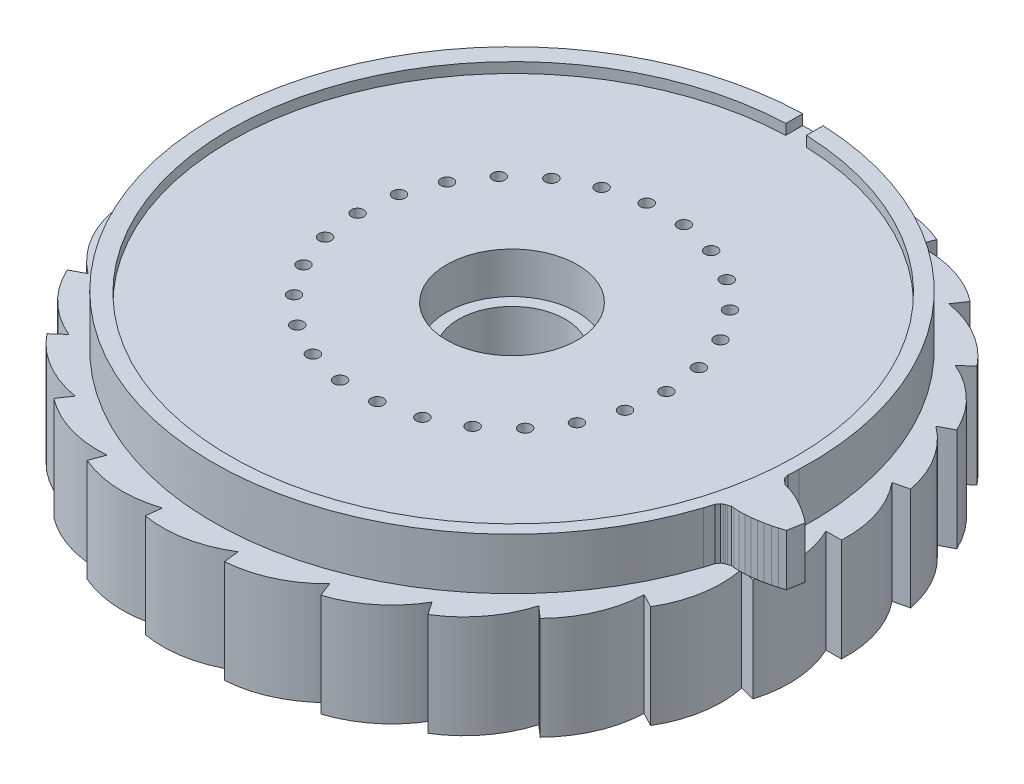
from build123d import *

# Parameters (mm, degrees)
EXTRUDE_RATCHET_EDGE_DEPTH      = 10
PATTERN_EDGE_TO_FORM_GEAR_COUNT = 26
GEAR_FACE_DEPTH                 = 5
PCB_INSET_DEPTH                 = 1
SKETCH7_R                       = 6.35
CUT_BEARING_HOLE_DEPTH          = 5
PCB_INSET_REAR_DEPTH            = 1
PIN_HOLES_R                     = 0.6
PIN_HOLES_CUT_DEPTH             = 15
SKETCH15_R                      = 5.18
CUT_EXTRUDE3_DEPTH              = 16


with BuildPart() as part:
    # Sketch1 → Extrude ratchet edge (new body)
    with BuildSketch(Plane(origin=(0, 0, 0), x_dir=(1, 0, 0), z_dir=(0, 1, 0))):
        with BuildLine():
            Line((0, 0), (29.613725431, 7.299127761))
            ThreePointArc((29.613725431, 7.299127761), (31.486736206, 3.871832194), (32, 0))
            Line((32, 0), (0, 0))
        make_face()
    extrude_ratchet_edge = extrude(amount=EXTRUDE_RATCHET_EDGE_DEPTH)

    # Pattern edge to form gear: Extrude ratchet edge ×26 about axis
    pattern_edge_to_form_gear_axis = Axis((0, 0, 0), (0, 1, 0))
    for i in range(1, PATTERN_EDGE_TO_FORM_GEAR_COUNT):
        add(extrude_ratchet_edge.rotate(pattern_edge_to_form_gear_axis, i * 360 / PATTERN_EDGE_TO_FORM_GEAR_COUNT))

    # Sketch12 → Gear face (add)
    with BuildSketch(Plane(origin=(0, 10, 0), x_dir=(1, 0, 0), z_dir=(0, 1, 0))):
        with BuildLine():
            Line((28.927375325, -2.125741727), (29.026395325, -2.515151727))
            Line((29.026395325, -2.515151727), (29.142735325, -2.671831727))
            Line((29.142735325, -2.671831727), (29.262305325, -2.787261727))
            Line((29.262305325, -2.787261727), (29.383725325, -2.880131727))
            Line((29.383725325, -2.880131727), (29.624225325, -3.082071727))
            Line((29.624225325, -3.082071727), (29.879175325, -3.139941727))
            Line((29.879175325, -3.139941727), (30.384275325, -3.299211727))
            Line((30.384275325, -3.299211727), (30.884385325, -3.499611727))
            Line((30.884385325, -3.499611727), (31.379885325, -3.733371727))
            Line((31.379885325, -3.733371727), (31.870755325, -3.996551727))
            Line((31.870755325, -3.996551727), (32.356805325, -4.286661727))
            Line((32.356805325, -4.286661727), (32.837785325, -4.602001727))
            Line((32.837785325, -4.602001727), (33.313375325, -4.941291727))
            Line((33.313375325, -4.941291727), (33.783255325, -5.303521727))
            Line((33.783255325, -5.303521727), (33.502035325, -6.859281727))
            Line((33.502035325, -6.859281727), (32.935085325, -7.034091727))
            Line((32.935085325, -7.034091727), (32.370805325, -7.185411727))
            Line((32.370805325, -7.185411727), (31.809875325, -7.312411727))
            Line((31.809875325, -7.312411727), (31.253015325, -7.414011727))
            Line((31.253015325, -7.414011727), (30.701075325, -7.488691727))
            Line((30.701075325, -7.488691727), (30.155095325, -7.534201727))
            Line((30.155095325, -7.534201727), (29.616475325, -7.546831727))
            Line((29.616475325, -7.546831727), (29.087575325, -7.519191727))
            Line((29.087575325, -7.519191727), (28.828505325, -7.484151727))
            Line((28.828505325, -7.484151727), (28.532525325, -7.589111727))
            Line((28.532525325, -7.589111727), (28.386275325, -7.633601727))
            Line((28.386275325, -7.633601727), (28.233865325, -7.699871727))
            Line((28.233865325, -7.699871727), (28.070045325, -7.805911727))
            Line((28.070045325, -7.805911727), (27.840955325, -8.136001727))
            Line((27.840955325, -8.136001727), (27.578045325, -8.986971727))
            ThreePointArc((27.578045325, -8.986971727), (-28.554449146, 5.09486788), (28.984351964, -1.105253821))
            Line((28.984351964, -1.105253821), (28.927375325, -2.125741727))
        make_face()
    extrude(amount=GEAR_FACE_DEPTH)

    # Sketch10 → PCB inset (cut)
    with BuildSketch(Plane(origin=(0, 15, 0), x_dir=(1, 0, 0), z_dir=(0, 1, 0))):
        with BuildLine():
            Line((-0.753755436, 29.351723584), (-0.753755436, 27.351723584))
            ThreePointArc((-0.753755436, 27.351723584), (0.246244564, -27.630088583), (1.246244564, 27.351723584))
            Line((1.246244564, 27.351723584), (1.246244564, 29.351723584))
            Line((1.246244564, 29.351723584), (-0.753755436, 29.351723584))
        make_face()
    extrude(amount=-PCB_INSET_DEPTH, mode=Mode.SUBTRACT)

    # Sketch7 → Cut bearing hole (cut)
    with BuildSketch(Plane(origin=(0, 15, 0), x_dir=(1, 0, 0), z_dir=(0, 1, 0))):
        Circle(SKETCH7_R)
    extrude(amount=-CUT_BEARING_HOLE_DEPTH, mode=Mode.SUBTRACT)

    # Sketch11 → PCB inset rear (cut)
    with BuildSketch(Plane.XZ):
        with BuildLine():
            Line((1, -29.481812167), (1, -27.481812167))
            ThreePointArc((1, -27.481812167), (0, 27.5), (-1, -27.481812167))
            Line((-1, -27.481812167), (-1, -29.481812167))
            Line((-1, -29.481812167), (1, -29.481812167))
        make_face()
    extrude(amount=-PCB_INSET_REAR_DEPTH, mode=Mode.SUBTRACT)

    # pin holes → Pin holes cut (cut, through all)
    with BuildSketch(Plane(origin=(0, 14, 0), x_dir=(1, 0, 0), z_dir=(0, 1, 0))):
        with Locations((15, 0)):
            Circle(PIN_HOLES_R)
        with Locations((14.564127261, -3.589734964)):
            Circle(PIN_HOLES_R)
        with Locations((13.281840385, -6.970847581)):
            Circle(PIN_HOLES_R)
        with Locations((11.227661223, -9.946839874)):
            Circle(PIN_HOLES_R)
        with Locations((8.520971201, -12.344757988)):
            Circle(PIN_HOLES_R)
        with Locations((5.319073306, -14.02524364)):
            Circle(PIN_HOLES_R)
        with Locations((1.808050204, -14.890633111)):
            Circle(PIN_HOLES_R)
        with Locations((-1.808050204, -14.890633111)):
            Circle(PIN_HOLES_R)
        with Locations((-5.319073306, -14.02524364)):
            Circle(PIN_HOLES_R)
        with Locations((-8.520971201, -12.344757988)):
            Circle(PIN_HOLES_R)
        with Locations((-11.227661223, -9.946839874)):
            Circle(PIN_HOLES_R)
        with Locations((-13.281840385, -6.970847581)):
            Circle(PIN_HOLES_R)
        with Locations((-14.564127261, -3.589734964)):
            Circle(PIN_HOLES_R)
        with Locations((-15, 0)):
            Circle(PIN_HOLES_R)
        with Locations((-14.564127261, 3.589734964)):
            Circle(PIN_HOLES_R)
        with Locations((-13.281840385, 6.970847581)):
            Circle(PIN_HOLES_R)
        with Locations((-11.227661223, 9.946839874)):
            Circle(PIN_HOLES_R)
        with Locations((-8.520971201, 12.344757988)):
            Circle(PIN_HOLES_R)
        with Locations((-5.319073306, 14.02524364)):
            Circle(PIN_HOLES_R)
        with Locations((-1.808050204, 14.890633111)):
            Circle(PIN_HOLES_R)
        with Locations((1.808050204, 14.890633111)):
            Circle(PIN_HOLES_R)
        with Locations((5.319073306, 14.02524364)):
            Circle(PIN_HOLES_R)
        with Locations((8.520971201, 12.344757988)):
            Circle(PIN_HOLES_R)
        with Locations((11.227661223, 9.946839874)):
            Circle(PIN_HOLES_R)
        with Locations((13.281840385, 6.970847581)):
            Circle(PIN_HOLES_R)
        with Locations((14.564127261, 3.589734964)):
            Circle(PIN_HOLES_R)
    extrude(amount=-PIN_HOLES_CUT_DEPTH, mode=Mode.SUBTRACT)

    # Sketch15 → Cut-Extrude3 (cut, through all)
    with BuildSketch(Plane.XZ):
        Circle(SKETCH15_R)
    extrude(amount=-CUT_EXTRUDE3_DEPTH, mode=Mode.SUBTRACT)


solid = part.part
